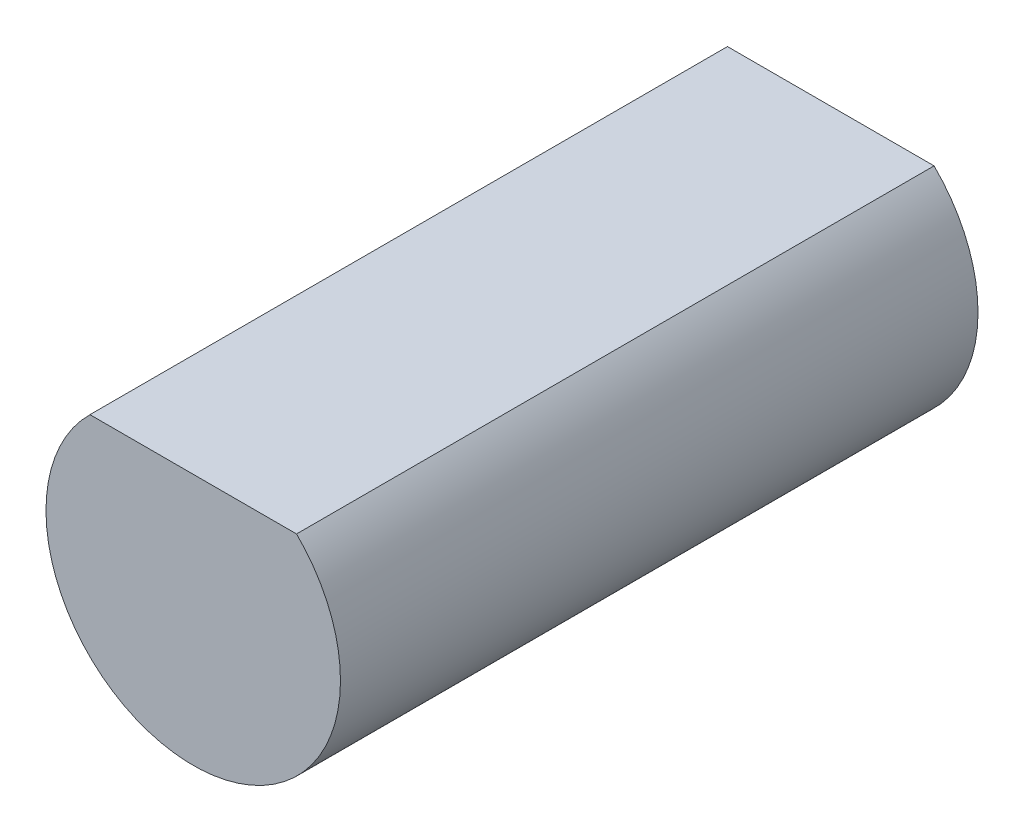
from build123d import *

# Parameters (mm, degrees)
BOSS_EXTRUDE1_DEPTH = 17.32


with BuildPart() as part:
    # Sketch2 → Boss-Extrude1 (new body)
    with BuildSketch(Plane.XY):
        with BuildLine():
            Line((-2.80668844, 2.85), (2.80668844, 2.85))
            ThreePointArc((2.80668844, 2.85), (0, -4), (-2.80668844, 2.85))
        make_face()
    extrude(amount=BOSS_EXTRUDE1_DEPTH)


solid = part.part
